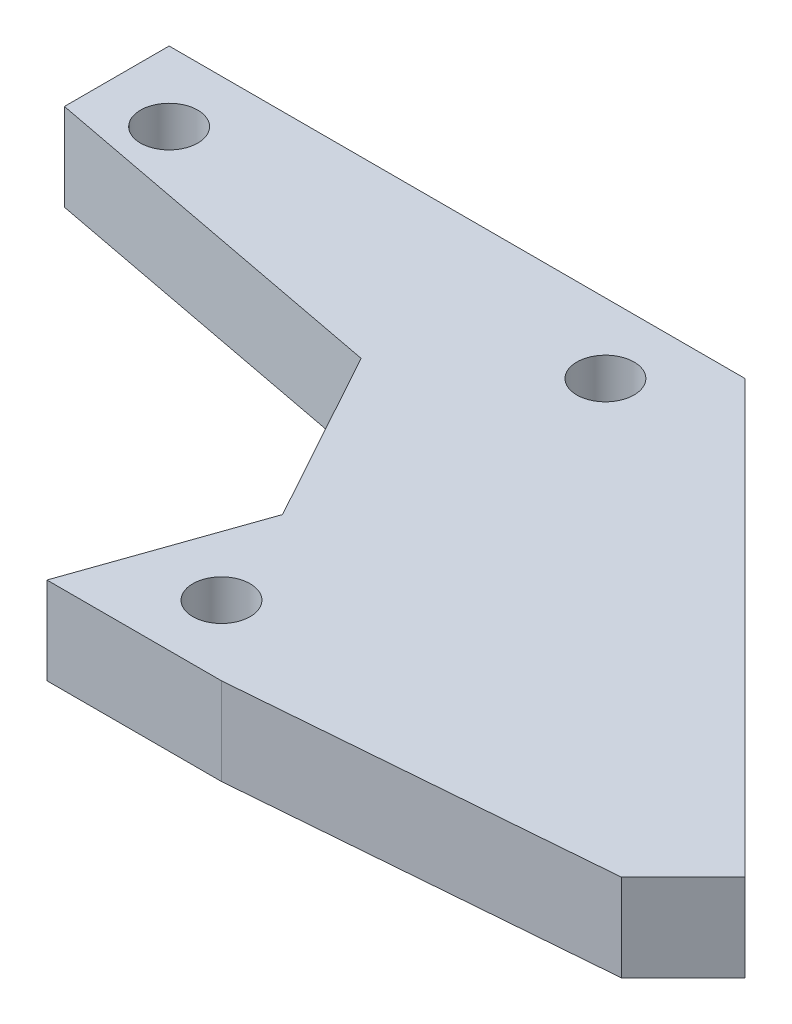
from build123d import *

# Parameters (mm, degrees)
SKETCH2_R           = 2.0828
BOSS_EXTRUDE1_DEPTH = 6.35


with BuildPart() as part:
    # Sketch2 → Boss-Extrude1 (new body)
    with BuildSketch(Plane(origin=(0, 0, 0), x_dir=(1, 0, 0), z_dir=(0, 1, 0))):
        Polygon((63.5, 19.05), (94.930896424, -12.380896424), (90.440768363, -16.871024484), (63.5, -19.05), (50.8, -19.05), (55.245, -6.35), (48.26, 6.35), (21.59, 11.43), (21.59, 19.05), align=None)
        with Locations((58.42, 13.97)):
            Circle(SKETCH2_R, mode=Mode.SUBTRACT)
        with Locations((26.67, 13.97)):
            Circle(SKETCH2_R, mode=Mode.SUBTRACT)
        with Locations((58.42, -13.97)):
            Circle(SKETCH2_R, mode=Mode.SUBTRACT)
    extrude(amount=BOSS_EXTRUDE1_DEPTH)


solid = part.part
